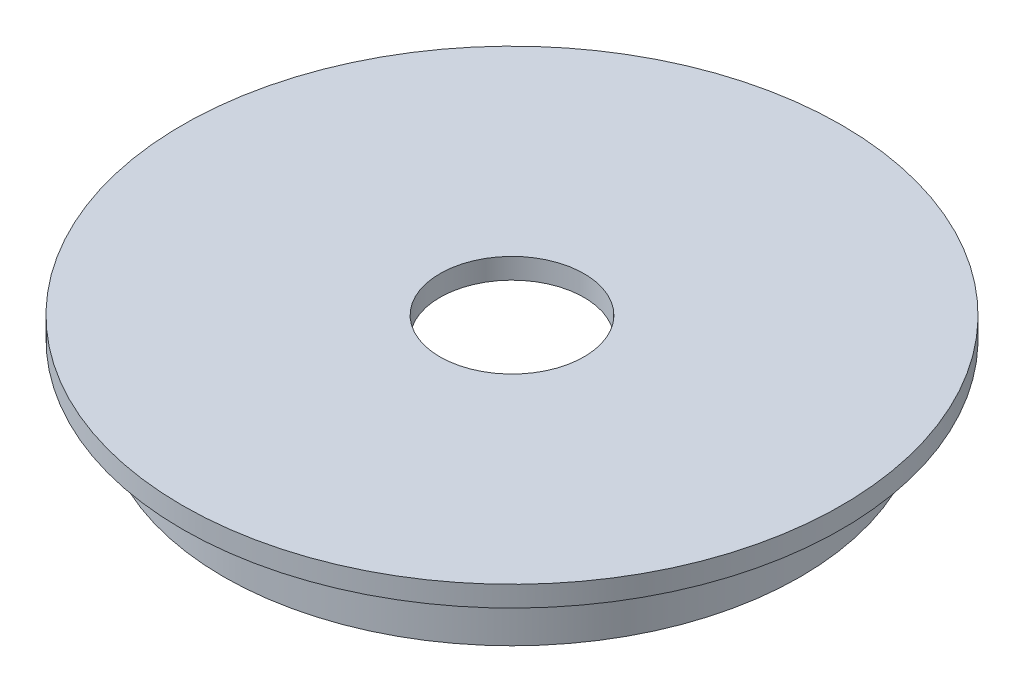
from build123d import *

# Parameters (mm, degrees)
SKETCH2_R          = 41.275
CUT_EXTRUDE1_DEPTH = 9.525
SKETCH3_R          = 11.1125
CUT_EXTRUDE2_DEPTH = 13.7


with BuildPart() as part:
    # Sketch1 → Revolve1 (revolve)
    with BuildSketch(Plane.XY):
        Polygon((0, 0), (-50.8, 0), (-50.8, -3.175), (-44.45, -3.175), (-44.45, -12.7), (0, -12.7), align=None)
    revolve(axis=Axis((0, -12.7, 0), (0, 1, 0)))

    # Sketch2 → Cut-Extrude1 (cut)
    with BuildSketch(Plane.XZ.offset(12.7)):
        Circle(SKETCH2_R)
    extrude(amount=-CUT_EXTRUDE1_DEPTH, mode=Mode.SUBTRACT)

    # Sketch3 → Cut-Extrude2 (cut, through all)
    with BuildSketch(Plane(origin=(0, 0, 0), x_dir=(1, 0, 0), z_dir=(0, 1, 0))):
        Circle(SKETCH3_R)
    extrude(amount=-CUT_EXTRUDE2_DEPTH, mode=Mode.SUBTRACT)


solid = part.part
